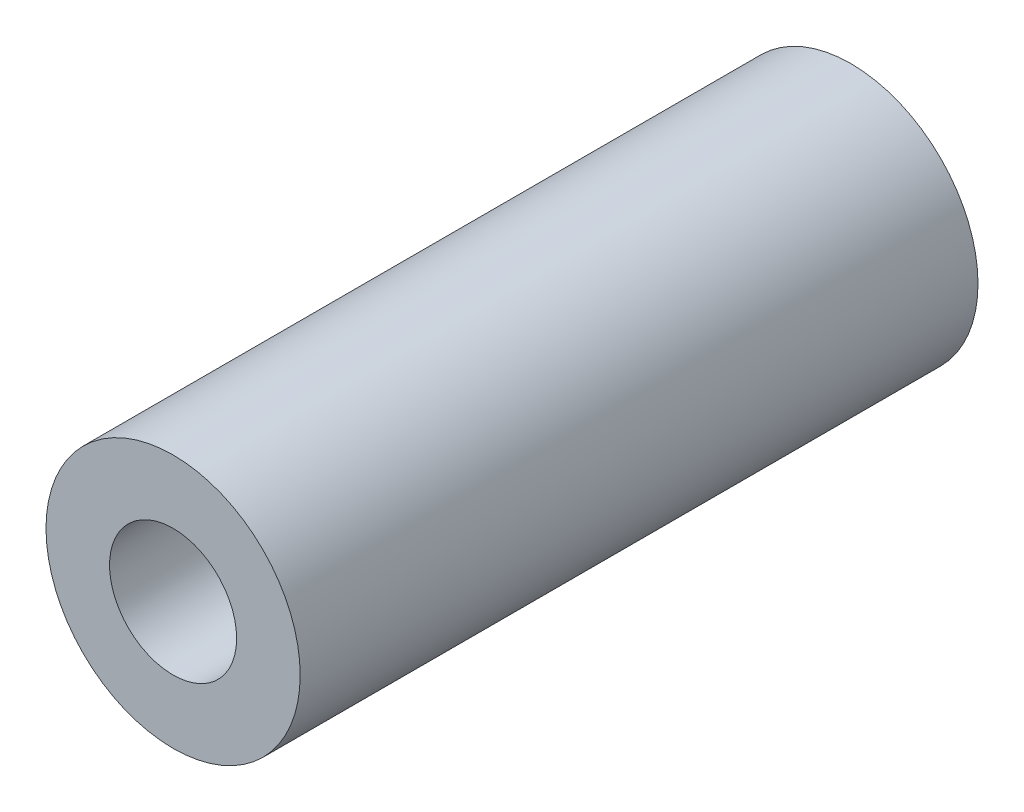
from build123d import *

# Parameters (mm, degrees)
SKETCH1_R           = 3
SKETCH1_R_2         = 1.5
BOSS_EXTRUDE1_DEPTH = 16


with BuildPart() as part:
    # Sketch1 → Boss-Extrude1 (new body)
    with BuildSketch(Plane.XY):
        Circle(SKETCH1_R)
        Circle(SKETCH1_R_2, mode=Mode.SUBTRACT)
    extrude(amount=BOSS_EXTRUDE1_DEPTH)


solid = part.part
